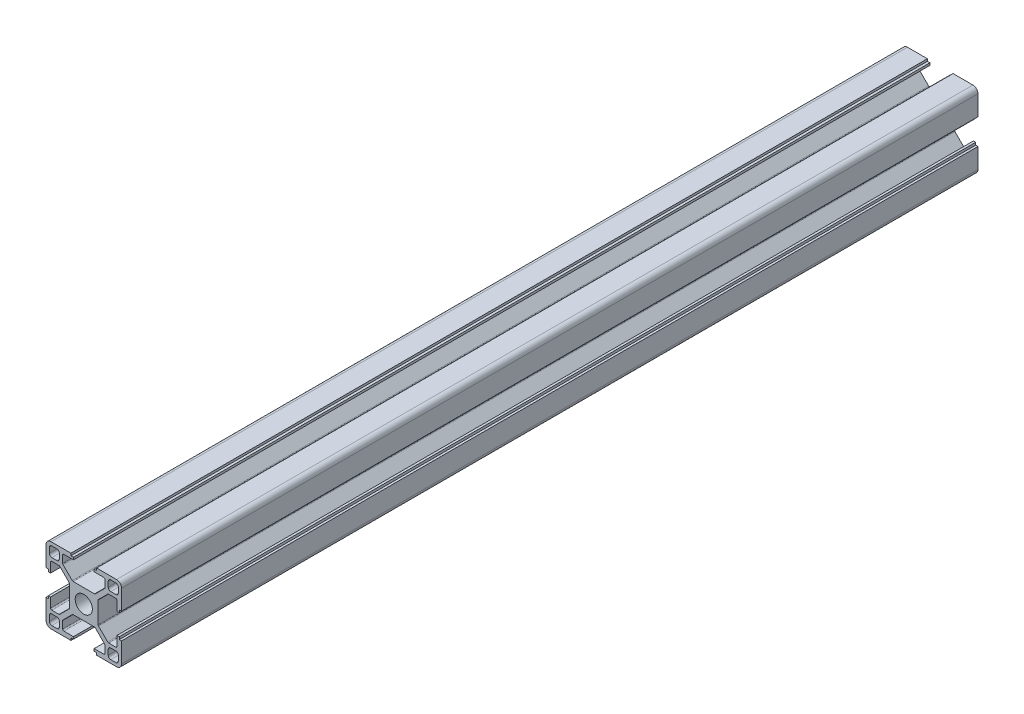
from build123d import *

# Parameters (mm, degrees)
SKETCH_1_W                       = 4
SKETCH_1_H                       = 4
EXTRUDE_1_DEPTH                  = 340
FILLET_1_R                       = 1
FILLET_2_R                       = 2
FILLET_3_R                       = 0.5
PATTERN_CIRCULAR_1_COUNT         = 4
FILLET_1_OF_PATTERN_CIRCULAR_1_R = 1
FILLET_2_OF_PATTERN_CIRCULAR_1_R = 2
FILLET_3_OF_PATTERN_CIRCULAR_1_R = 0.5
SKETCH_2_R                       = 3.4
CUT_EXTRUDE_1_DEPTH              = 341
SKETCH_3_R                       = 3.15
CUT_EXTRUDE_2_DEPTH              = 10


with BuildPart() as part:
    # 草图1 → 凸台-拉伸1 (new body)
    with BuildSketch(Plane.XY):
        Polygon((5.7, 0), (5.7, 4.427207794), (9.672792206, 8.4), (13.2, 8.4), (13.2, 4.1), (14.1, 4.1), (14.1, 5.1), (15, 5.1), (15, 15), (5.1, 15), (5.1, 14.1), (4.1, 14.1), (4.1, 13.2), (8.4, 13.2), (8.4, 9.672792206), (4.427207794, 5.7), (0, 5.7), (0, 0), align=None)
        with Locations((11.7, 11.7)):
            Rectangle(SKETCH_1_W, SKETCH_1_H, mode=Mode.SUBTRACT)
    extrude_1 = extrude(amount=EXTRUDE_1_DEPTH)

    # 圆角1
    fillet_1_edges = [part.edges().sort_by_distance(p)[0] for p in [
        (13.7, 9.7, 170),
        (13.7, 13.7, 170),
        (9.7, 13.7, 170),
        (9.7, 9.7, 170),
    ]]
    fillet(fillet_1_edges, radius=FILLET_1_R)

    # 圆角2
    fillet_2_edges = [part.edges().sort_by_distance(p)[0] for p in [
        (15, 15, 170),
    ]]
    fillet(fillet_2_edges, radius=FILLET_2_R)

    # 圆角3
    fillet_3_edges = [part.edges().sort_by_distance(p)[0] for p in [
        (4.427207794, 5.7, 170),
        (8.4, 9.672792206, 170),
        (8.4, 13.2, 170),
        (13.2, 8.4, 170),
        (9.672792206, 8.4, 170),
        (5.7, 4.427207794, 170),
    ]]
    fillet(fillet_3_edges, radius=FILLET_3_R)

    # 阵列(圆周)1: 凸台-拉伸1 ×4 about axis
    pattern_circular_1_axis = Axis((0, 0, 0), (0, 0, 1))
    for i in range(1, PATTERN_CIRCULAR_1_COUNT):
        add(extrude_1.rotate(pattern_circular_1_axis, i * 360 / PATTERN_CIRCULAR_1_COUNT))

    # 圆角1 of 阵列(圆周)1
    fillet_1_of_pattern_circular_1_edges = [part.edges().sort_by_distance(p)[0] for p in [
        (-9.7, 13.7, 170),
        (-13.7, 13.7, 170),
        (-13.7, 9.7, 170),
        (-9.7, 9.7, 170),
        (-13.7, -9.7, 170),
        (-13.7, -13.7, 170),
        (-9.7, -13.7, 170),
        (-9.7, -9.7, 170),
        (9.7, -13.7, 170),
        (13.7, -13.7, 170),
        (13.7, -9.7, 170),
        (9.7, -9.7, 170),
    ]]
    fillet(fillet_1_of_pattern_circular_1_edges, radius=FILLET_1_OF_PATTERN_CIRCULAR_1_R)

    # 圆角2 of 阵列(圆周)1
    fillet_2_of_pattern_circular_1_edges = [part.edges().sort_by_distance(p)[0] for p in [
        (-15, 15, 170),
        (-15, -15, 170),
        (15, -15, 170),
    ]]
    fillet(fillet_2_of_pattern_circular_1_edges, radius=FILLET_2_OF_PATTERN_CIRCULAR_1_R)

    # 圆角3 of 阵列(圆周)1
    fillet_3_of_pattern_circular_1_edges = [part.edges().sort_by_distance(p)[0] for p in [
        (-5.7, 4.427207794, 170),
        (-9.672792206, 8.4, 170),
        (-13.2, 8.4, 170),
        (-8.4, 13.2, 170),
        (-8.4, 9.672792206, 170),
        (-4.427207794, 5.7, 170),
        (-4.427207794, -5.7, 170),
        (-8.4, -9.672792206, 170),
        (-8.4, -13.2, 170),
        (-13.2, -8.4, 170),
        (-9.672792206, -8.4, 170),
        (-5.7, -4.427207794, 170),
        (5.7, -4.427207794, 170),
        (9.672792206, -8.4, 170),
        (13.2, -8.4, 170),
        (8.4, -13.2, 170),
        (8.4, -9.672792206, 170),
        (4.427207794, -5.7, 170),
    ]]
    fillet(fillet_3_of_pattern_circular_1_edges, radius=FILLET_3_OF_PATTERN_CIRCULAR_1_R)

    # 草图2 → 切除-拉伸1 (cut, through all)
    with BuildSketch(Plane.XY.offset(340)):
        Circle(SKETCH_2_R)
    extrude(amount=-CUT_EXTRUDE_1_DEPTH, mode=Mode.SUBTRACT)

    # 草图3 → 切除-拉伸2 (cut, symmetric)
    with BuildSketch(Plane(origin=(0, 0, 0), x_dir=(0, 0, -1), z_dir=(1, 0, 0))):
        with Locations((-185, 0)):
            Circle(SKETCH_3_R)
        with Locations((-155, 0)):
            Circle(SKETCH_3_R)
    extrude(amount=CUT_EXTRUDE_2_DEPTH, both=True, mode=Mode.SUBTRACT)


solid = part.part
